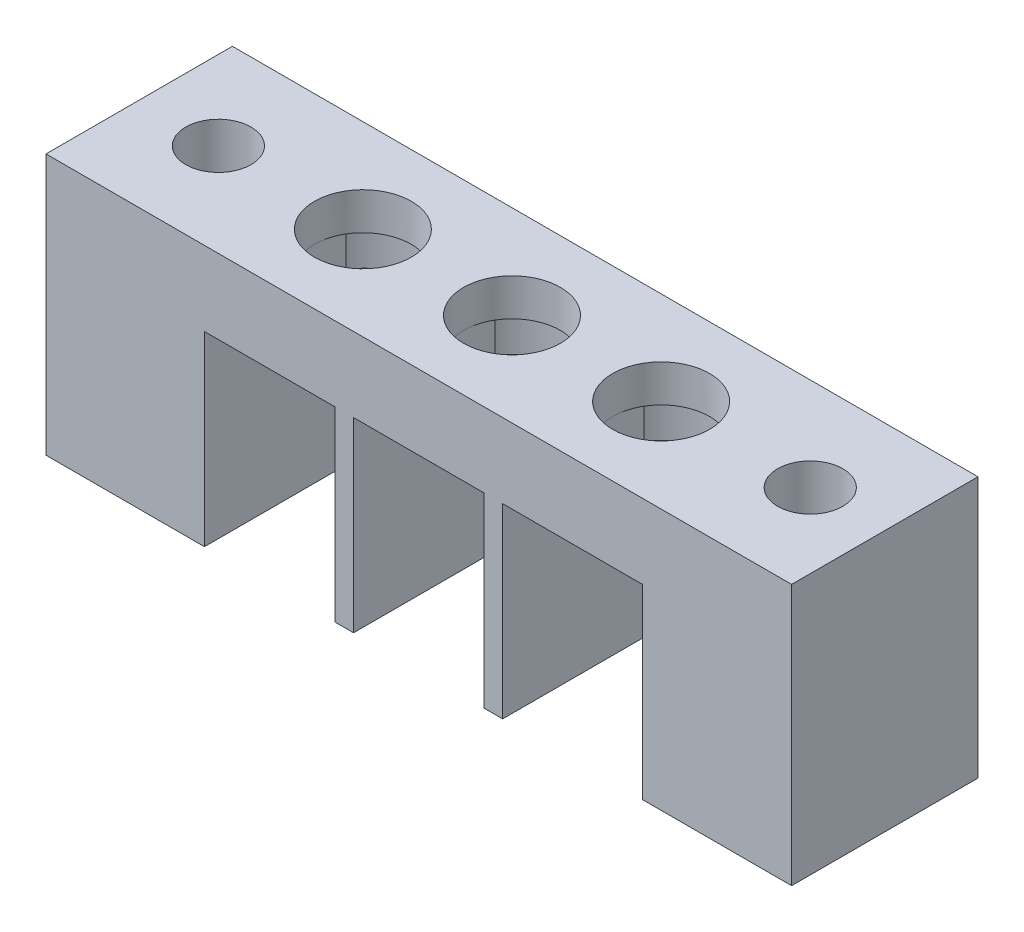
from build123d import *

# Parameters (mm, degrees)
SKETCH1_W           = 32
SKETCH1_H           = 10
BOSS_EXTRUDE1_DEPTH = 4
SKETCH2_R           = 2.6
CUT_EXTRUDE1_DEPTH  = 10
CUT_EXTRUDE4_DEPTH  = 2
BOSS_EXTRUDE4_DEPTH = 10
SKETCH9_W           = 10
SKETCH9_H           = 14
BOSS_EXTRUDE5_DEPTH = 4
SKETCH10_W          = 10
SKETCH10_H          = 14
BOSS_EXTRUDE6_DEPTH = 4
SKETCH6_R           = 1.75
CUT_EXTRUDE5_DEPTH  = 40
CUT_EXTRUDE6_DEPTH  = 5


with BuildPart() as part:
    # Sketch1 → Boss-Extrude1 (new body)
    with BuildSketch(Plane(origin=(0, 0, 0), x_dir=(1, 0, 0), z_dir=(0, 1, 0))):
        with Locations((-1, -2.382550336)):
            Rectangle(SKETCH1_W, SKETCH1_H)
    extrude(amount=BOSS_EXTRUDE1_DEPTH)

    # Sketch2 → Cut-Extrude1 (cut)
    with BuildSketch(Plane(origin=(0, 4, 0), x_dir=(1, 0, 0), z_dir=(0, 1, 0))):
        with Locations((-9, -2.382550336)):
            Circle(SKETCH2_R)
        with Locations((-1, -2.382550336)):
            Circle(SKETCH2_R)
        with Locations((7, -2.382550336)):
            Circle(SKETCH2_R)
    extrude(amount=-CUT_EXTRUDE1_DEPTH, mode=Mode.SUBTRACT)

    # Sketch3 → Cut-Extrude4 (cut)
    with BuildSketch(Plane.XZ):
        with BuildLine():
            Line((-11.6, 4.070744637), (-11.6, 0.694356034))
            ThreePointArc((-11.6, 0.694356034), (-5.9, 2.382550336), (-11.6, 4.070744637))
        make_face()
        with BuildLine():
            Line((-3.6, 4.070744637), (-3.6, 0.694356034))
            ThreePointArc((-3.6, 0.694356034), (2.1, 2.382550336), (-3.6, 4.070744637))
        make_face()
        with BuildLine():
            Line((4.4, 4.070744637), (4.4, 0.694356034))
            ThreePointArc((4.4, 0.694356034), (10.1, 2.382550336), (4.4, 4.070744637))
        make_face()
    extrude(amount=-CUT_EXTRUDE4_DEPTH, mode=Mode.SUBTRACT)

    # Sketch5 → Boss-Extrude4 (add)
    with BuildSketch(Plane.XZ):
        Polygon((-17, -1.617449664), (-17, -2.617449664), (15, -2.617449664), (15, -1.617449664), (15, 7.382550336), (11, 7.382550336), (11, -1.617449664), (3.5, -1.617449664), (3.5, 7.382550336), (2.5, 7.382550336), (2.5, -1.617449664), (-4.5, -1.617449664), (-4.5, 7.382550336), (-5.5, 7.382550336), (-5.5, -1.617449664), (-12.5, -1.617449664), (-12.5, 7.382550336), (-13, 7.382550336), (-13.5, 7.382550336), (-17, 7.382550336), align=None)
    extrude(amount=BOSS_EXTRUDE4_DEPTH)

    # Sketch9 → Boss-Extrude5 (add)
    with BuildSketch(Plane(origin=(15, 0, 0), x_dir=(0, 0, -1), z_dir=(1, 0, 0))):
        with Locations((-2.382550336, -3)):
            Rectangle(SKETCH9_W, SKETCH9_H)
    extrude(amount=BOSS_EXTRUDE5_DEPTH)

    # Sketch10 → Boss-Extrude6 (add)
    with BuildSketch(Plane.ZY.offset(17)):
        with Locations((2.382550336, -3)):
            Rectangle(SKETCH10_W, SKETCH10_H)
    extrude(amount=BOSS_EXTRUDE6_DEPTH)

    # Sketch6 → Cut-Extrude5 (cut)
    with BuildSketch(Plane.XZ.offset(10)):
        with Locations((-16.75, 2.382550336)):
            Circle(SKETCH6_R)
        with Locations((15, 2.382550336)):
            Circle(SKETCH6_R)
    extrude(amount=-CUT_EXTRUDE5_DEPTH, mode=Mode.SUBTRACT)

    # Sketch8 → Cut-Extrude6 (cut)
    with BuildSketch(Plane.XZ.offset(10)):
        Polygon((-16.839532769, 5.556714354), (-19.543673061, 3.892094692), (-19.454140291, 0.717930674), (-16.660467231, -0.791613683), (-13.956326939, 0.873005979), (-14.045859709, 4.047169998), align=None)
        Polygon((15, 5.557976816), (12.25, 3.970263576), (12.25, 0.794837095), (15, -0.792876145), (17.75, 0.794837095), (17.75, 3.970263576), align=None)
    extrude(amount=-CUT_EXTRUDE6_DEPTH, mode=Mode.SUBTRACT)


solid = part.part
